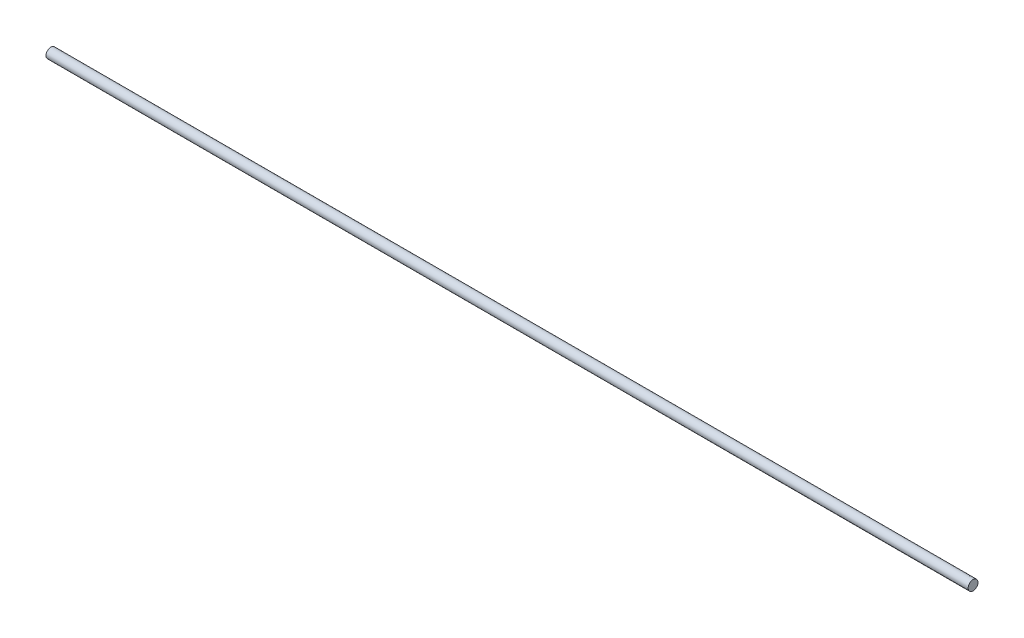
from build123d import *

# Parameters (mm, degrees)
SKETCH1_R           = 4
BOSS_EXTRUDE1_DEPTH = 750


with BuildPart() as part:
    # Sketch1 → Boss-Extrude1 (new body)
    with BuildSketch(Plane(origin=(0, 0, 0), x_dir=(0, 0, -1), z_dir=(1, 0, 0))):
        Circle(SKETCH1_R)
    extrude(amount=BOSS_EXTRUDE1_DEPTH)


solid = part.part
